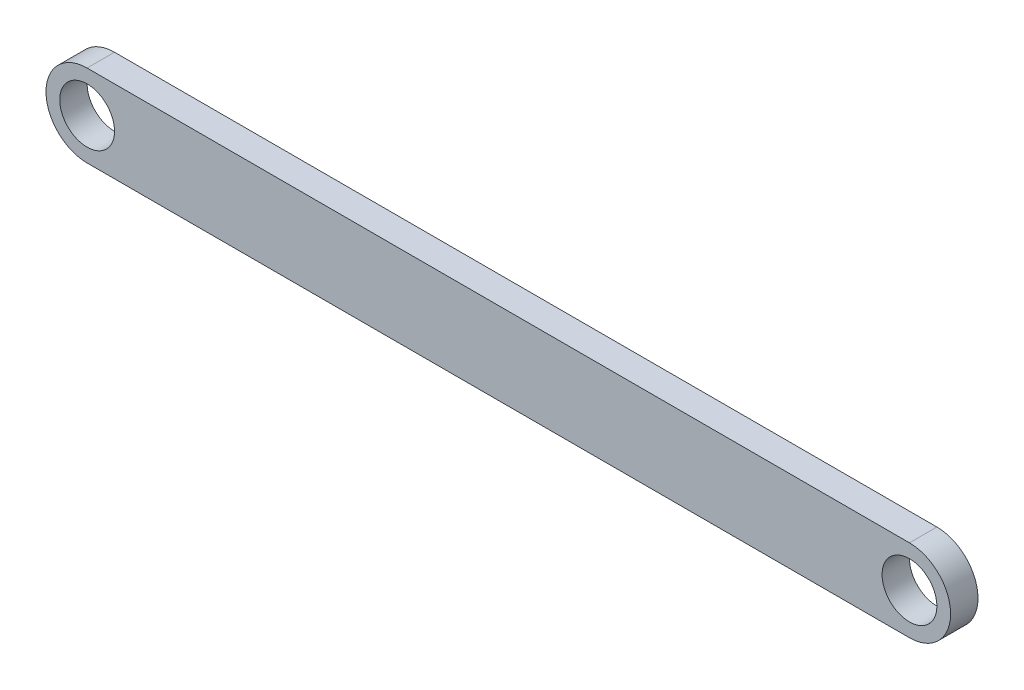
from build123d import *

# Parameters (mm, degrees)
SKETCH_1_R      = 2
EXTRUDE_1_DEPTH = 2


with BuildPart() as part:
    # 草图1 → 凸台-拉伸1 (new body)
    with BuildSketch(Plane.XY):
        with BuildLine():
            Line((-44.770643736, -3), (15.229356264, -3))
            ThreePointArc((15.229356264, -3), (18.229356264, 0), (15.229356264, 3))
            Line((15.229356264, 3), (-44.770643736, 3))
            ThreePointArc((-44.770643736, 3), (-47.770643736, 0), (-44.770643736, -3))
        make_face()
        with Locations((-44.770643736, 0)):
            Circle(SKETCH_1_R, mode=Mode.SUBTRACT)
        with Locations((15.229356264, 0)):
            Circle(SKETCH_1_R, mode=Mode.SUBTRACT)
    extrude(amount=EXTRUDE_1_DEPTH)


solid = part.part
